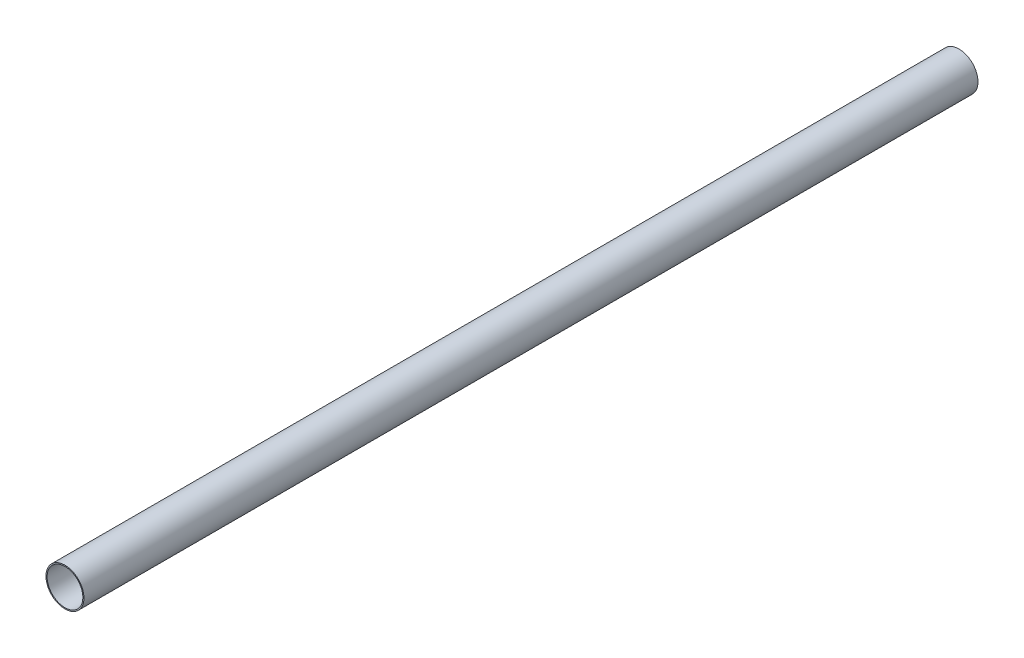
from build123d import *

# Parameters (mm, degrees)
CROQUIS1_R              = 4.25
CROQUIS1_R_2            = 4
SALIENTE_EXTRUIR1_DEPTH = 200


with BuildPart() as part:
    # Croquis1 → Saliente-Extruir1 (new body)
    with BuildSketch(Plane.XY):
        Circle(CROQUIS1_R)
        Circle(CROQUIS1_R_2, mode=Mode.SUBTRACT)
    extrude(amount=SALIENTE_EXTRUIR1_DEPTH)


solid = part.part
